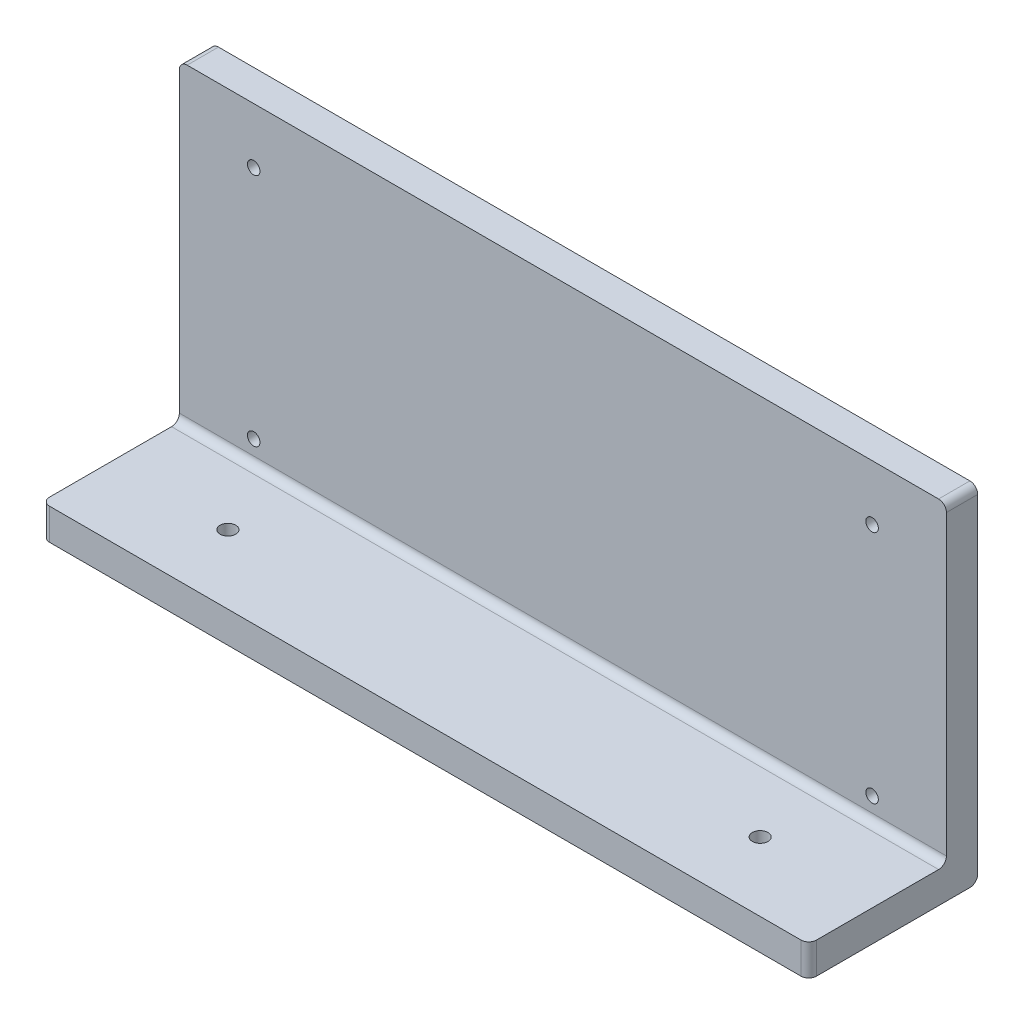
from build123d import *

# Parameters (mm, degrees)
SKETCH1_W           = 98
SKETCH1_H           = 21.59
BOSS_EXTRUDE1_DEPTH = 4
SKETCH2_W           = 98
SKETCH2_H           = 4
BOSS_EXTRUDE2_DEPTH = 40
SKETCH3_R           = 0.8
CUT_EXTRUDE1_DEPTH  = 21
FILLET1_R           = 1
SKETCH4_R           = 1
CUT_EXTRUDE2_DEPTH  = 21


with BuildPart() as part:
    # Sketch1 → Boss-Extrude1 (new body)
    with BuildSketch(Plane(origin=(0, 0, 0), x_dir=(1, 0, 0), z_dir=(0, 1, 0))):
        Rectangle(SKETCH1_W, SKETCH1_H)
    extrude(amount=BOSS_EXTRUDE1_DEPTH)

    # Sketch2 → Boss-Extrude2 (add)
    with BuildSketch(Plane(origin=(0, 4, 0), x_dir=(1, 0, 0), z_dir=(0, 1, 0))):
        with Locations((0, 8.795)):
            Rectangle(SKETCH2_W, SKETCH2_H)
    extrude(amount=BOSS_EXTRUDE2_DEPTH)

    # Sketch3 → Cut-Extrude1 (cut)
    with BuildSketch(Plane.XY.offset(-6.795)):
        with Locations((-39.5, 6.904051391)):
            Circle(SKETCH3_R)
        with Locations((-39.5, 36.904051391)):
            Circle(SKETCH3_R)
        with Locations((39.5, 36.904051391)):
            Circle(SKETCH3_R)
        with Locations((39.5, 6.904051391)):
            Circle(SKETCH3_R)
    extrude(amount=-CUT_EXTRUDE1_DEPTH, mode=Mode.SUBTRACT)

    # Fillet1
    fillet1_edges = [part.edges().sort_by_distance(p)[0] for p in [
        (0, 4, -6.795),
        (49, 44, -8.795),
        (-49, 44, -8.795),
        (0, 0, -10.795),
        (49, 2, 10.795),
        (-49, 2, 10.795),
    ]]
    fillet(fillet1_edges, radius=FILLET1_R)

    # Sketch4 → Cut-Extrude2 (cut)
    with BuildSketch(Plane(origin=(0, 4, 0), x_dir=(1, 0, 0), z_dir=(0, 1, 0))):
        with Locations((-34, -2)):
            Circle(SKETCH4_R)
        with Locations((34, -2)):
            Circle(SKETCH4_R)
    extrude(amount=-CUT_EXTRUDE2_DEPTH, mode=Mode.SUBTRACT)


solid = part.part
